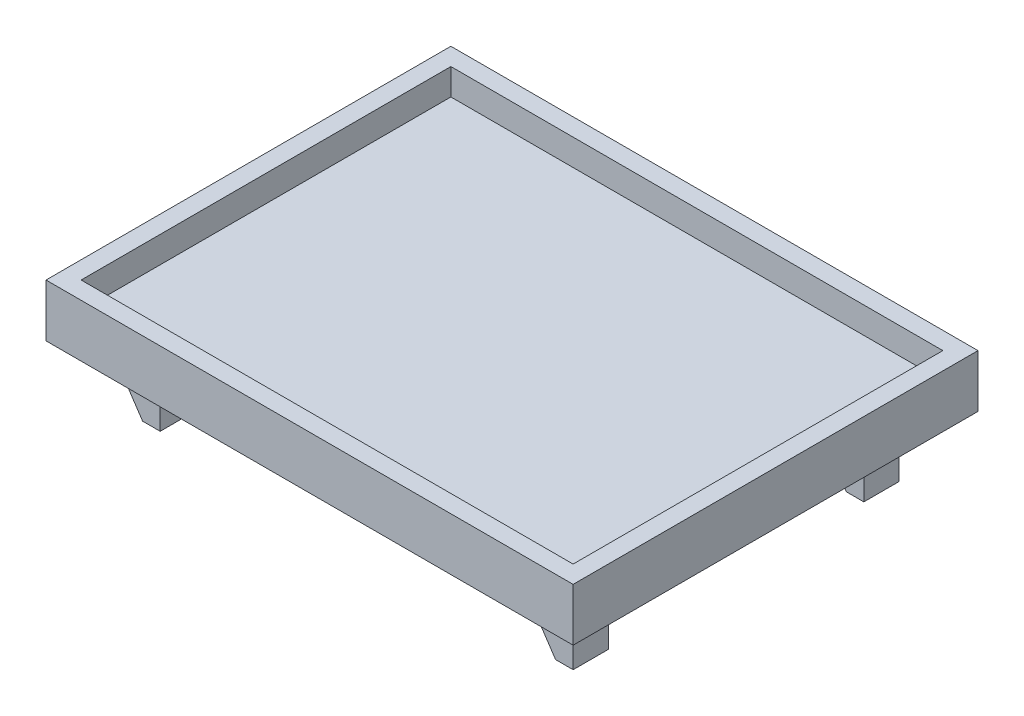
from build123d import *

# Parameters (mm, degrees)
SKETCH2_W           = 76.2254
SKETCH2_H           = 58.547
BOSS_EXTRUDE1_DEPTH = 7.62
SKETCH3_W           = 71.1454
SKETCH3_H           = 53.467
CUT_EXTRUDE2_DEPTH  = 3.81
SKETCH4_W           = 5.08
SKETCH4_H           = 5.08
BOSS_EXTRUDE2_DEPTH = 8.7884
CUT_EXTRUDE3_DEPTH  = 5.08


with BuildPart() as part:
    # Sketch2 → Boss-Extrude1 (new body)
    with BuildSketch(Plane(origin=(0, 0, 0), x_dir=(1, 0, 0), z_dir=(0, 1, 0))):
        Rectangle(SKETCH2_W, SKETCH2_H)
    extrude(amount=-BOSS_EXTRUDE1_DEPTH)

    # Sketch3 → Cut-Extrude2 (cut)
    with BuildSketch(Plane(origin=(0, 0, 0), x_dir=(1, 0, 0), z_dir=(0, 1, 0))):
        Rectangle(SKETCH3_W, SKETCH3_H)
    extrude(amount=-CUT_EXTRUDE2_DEPTH, mode=Mode.SUBTRACT)

    # Sketch4 → Boss-Extrude2 (add)
    with BuildSketch(Plane.XZ.offset(7.62)):
        with Locations((-29.8577, 21.0185)):
            Rectangle(SKETCH4_W, SKETCH4_H)
        with Locations((29.8577, 21.0185)):
            Rectangle(SKETCH4_W, SKETCH4_H)
    boss_extrude2 = extrude(amount=BOSS_EXTRUDE2_DEPTH)

    # Sketch5 → Cut-Extrude3 (cut)
    with BuildSketch(Plane.XY.offset(23.5585)):
        Polygon((29.8577, -16.4084), (27.3177, -16.4084), (27.3177, -12.606876095), align=None)
        Polygon((-29.8577, -16.4084), (-32.3977, -12.606876095), (-32.3977, -16.4084), align=None)
        Polygon((27.3177, -7.62), (27.3177, -11.336876095), (29.038774553, -10.798216701), (29.038774553, -7.62), align=None)
        Polygon((-32.3977, -11.336876095), (-30.676625447, -10.798216701), (-30.676625447, -7.62), (-32.3977, -7.62), align=None)
    cut_extrude3 = extrude(amount=-CUT_EXTRUDE3_DEPTH, mode=Mode.SUBTRACT)

    # Mirror1: Boss-Extrude2, Cut-Extrude3 across plane
    add(boss_extrude2.mirror(Plane.XY))
    add(cut_extrude3.mirror(Plane.XY), mode=Mode.SUBTRACT)


solid = part.part
